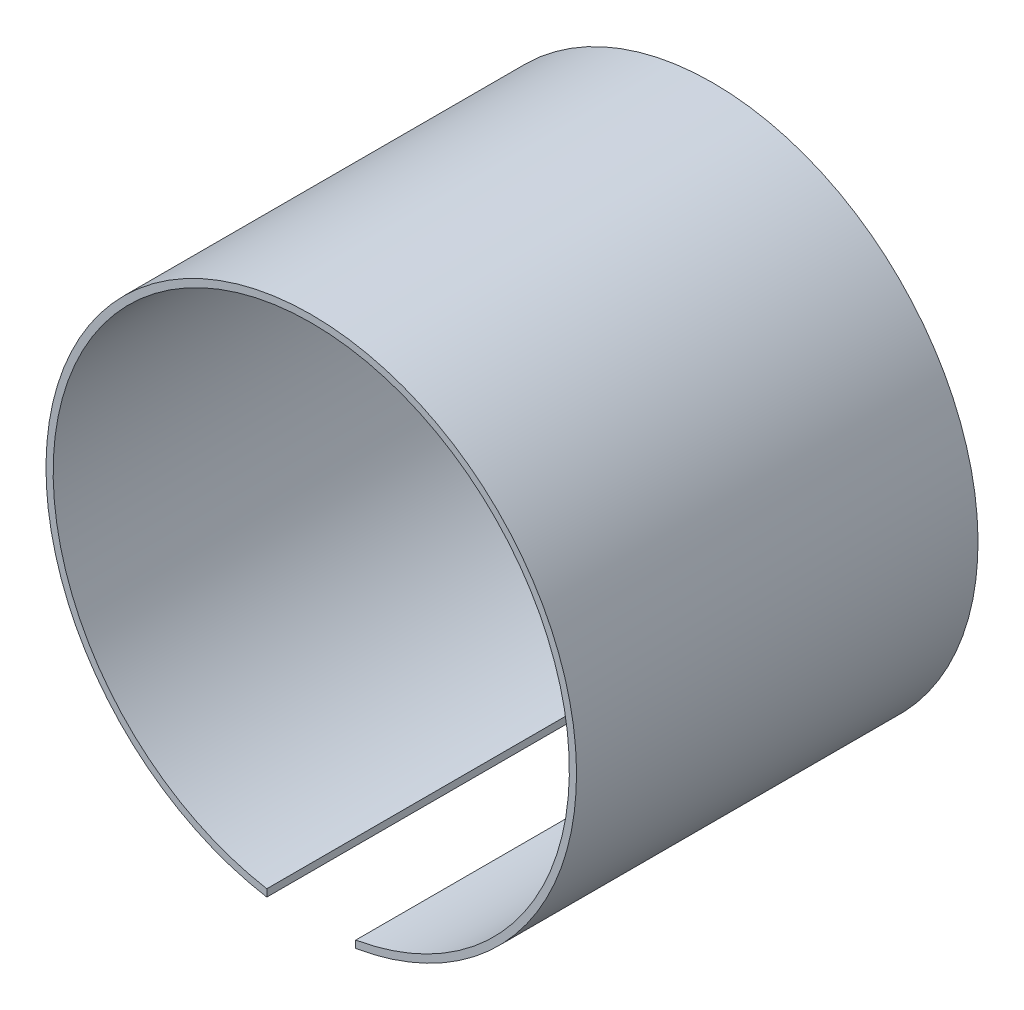
from build123d import *

# Parameters (mm, degrees)
SALIENTE_EXTRUIR1_DEPTH = 28


with BuildPart() as part:
    # Croquis1 → Saliente-Extruir1 (new body)
    with BuildSketch(Plane.XY):
        with BuildLine():
            Line((-3.1, -17.731046218), (-3.1, -18.238420984))
            ThreePointArc((-3.1, -18.238420984), (0, 18.5), (3.1, -18.238420984))
            Line((3.1, -18.238420984), (3.1, -17.731046218))
            ThreePointArc((3.1, -17.731046218), (0, 18), (-3.1, -17.731046218))
        make_face()
    extrude(amount=SALIENTE_EXTRUIR1_DEPTH)


solid = part.part
